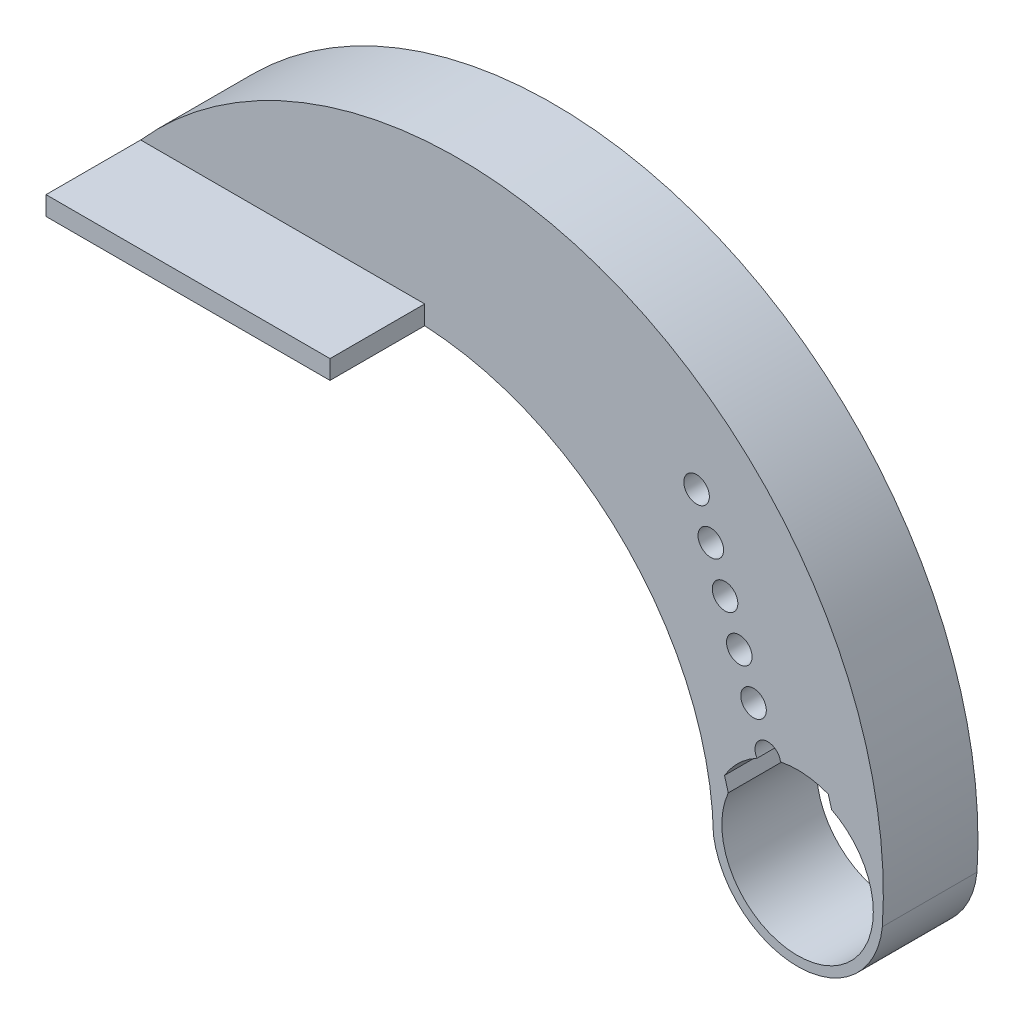
from build123d import *

# Parameters (mm, degrees)
BOSS_EXTRUDE1_DEPTH = 5
SKETCH1_3_W         = 15
SKETCH1_3_H         = 1
BOSS_EXTRUDE2_DEPTH = 10
BOSS_EXTRUDE3_START = 5
SKETCH1_4_R         = 0.675
BOSS_EXTRUDE3_DEPTH = 2.5


with BuildPart() as part:
    # Sketch1 → Boss-Extrude1 (new body)
    with BuildSketch(Plane.XY):
        with BuildLine():
            Line((-34.696792319, 15.960080691), (-34.696792319, 14.960080691))
            Line((-34.696792319, 14.960080691), (-19.696792319, 14.960080691))
            ThreePointArc((-19.696792319, 14.960080691), (-8.978328635, 10.128349866), (-4.442261745, -0.718547556))
            ThreePointArc((-4.442261745, -0.718547556), (0.138348196, -4.497872806), (4.478025356, -0.444172161))
            ThreePointArc((4.478025356, -0.444172161), (-9.240182202, 21.774129955), (-34.696792319, 15.960080691))
        make_face()
        with BuildLine():
            Line((-3.89291928, 2.43426562), (-7.593303854, 13.845333863))
            ThreePointArc((-7.593303854, 13.845333863), (-6.157572873, 16.914026296), (-3.083690723, 15.489440313))
            Line((-3.083690723, 15.489440313), (1.566927521, 4.392862954))
            Line((1.566927521, 4.392862954), (1.798943002, 3.572646648))
            ThreePointArc((1.798943002, 3.572646648), (1.351572105, -3.764738085), (-3.660510182, 1.612657808))
            Line((-3.660510182, 1.612657808), (-3.89291928, 2.43426562))
        make_face(mode=Mode.SUBTRACT)
    extrude(amount=BOSS_EXTRUDE1_DEPTH)

    # Sketch1_3 → Boss-Extrude2 (add)
    with BuildSketch(Plane.XY):
        with Locations((-27.196792319, 15.460080691)):
            Rectangle(SKETCH1_3_W, SKETCH1_3_H)
    extrude(amount=BOSS_EXTRUDE2_DEPTH)

    # Sketch1_4 → Boss-Extrude3 (add)
    with BuildSketch(Plane.XY.offset(BOSS_EXTRUDE3_START)):
        with BuildLine():
            Line((1.622209226, 4.197432218), (1.566927521, 4.392862954))
            Line((1.566927521, 4.392862954), (-3.083690723, 15.489440313))
            ThreePointArc((-3.083690723, 15.489440313), (-6.157572873, 16.914026296), (-7.593303854, 13.845333863))
            Line((-7.593303854, 13.845333863), (-3.89291928, 2.43426562))
            Line((-3.89291928, 2.43426562), (-3.859078085, 2.314630929))
            ThreePointArc((-3.859078085, 2.314630929), (-3.110655329, 3.251741598), (-2.141289558, 3.957888203))
            ThreePointArc((-2.141289558, 3.957888203), (-1.804156256, 4.956878575), (-0.903758531, 4.408312661))
            ThreePointArc((-0.903758531, 4.408312661), (0.374380142, 4.484399571), (1.622209226, 4.197432218))
        make_face()
        with Locations((-5.335514236, 14.659204884)):
            Circle(SKETCH1_4_R, mode=Mode.SUBTRACT)
        with Locations((-3.830625605, 10.524557353)):
            Circle(SKETCH1_4_R, mode=Mode.SUBTRACT)
        with Locations((-4.583069921, 12.591881119)):
            Circle(SKETCH1_4_R, mode=Mode.SUBTRACT)
        with Locations((-2.325736975, 6.389909821)):
            Circle(SKETCH1_4_R, mode=Mode.SUBTRACT)
        with Locations((-3.07818129, 8.457233587)):
            Circle(SKETCH1_4_R, mode=Mode.SUBTRACT)
    extrude(amount=-BOSS_EXTRUDE3_DEPTH)


solid = part.part
